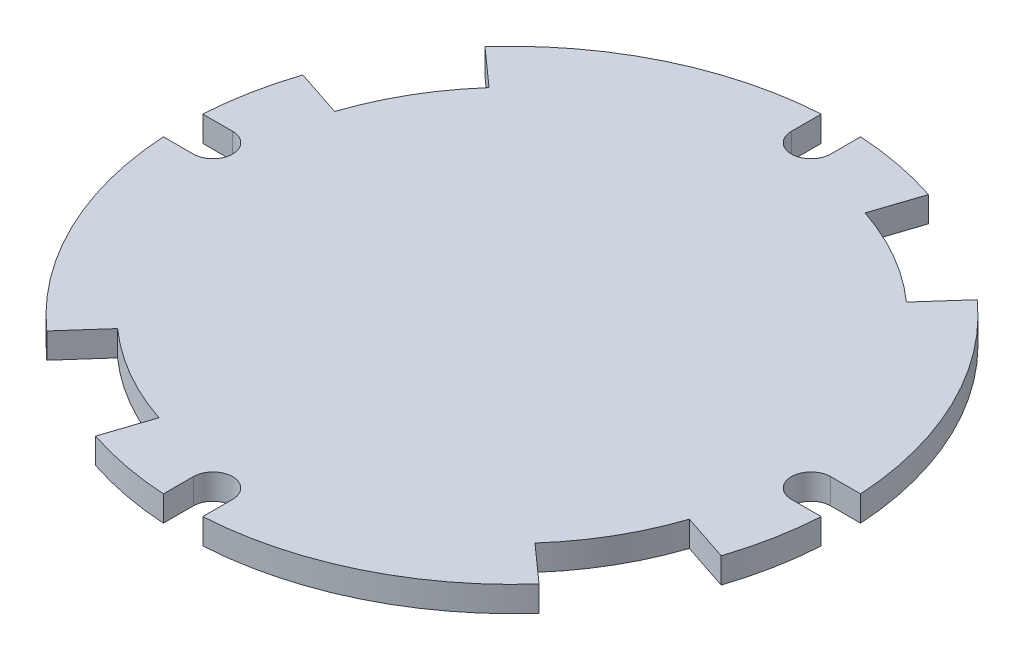
from build123d import *

# Parameters (mm, degrees)
ESQUISSE1_R                  = 25.95
BOSS_EXTRU_1_DEPTH           = 2
ENL_V_MAT_EXTRU_8_DEPTH      = 2
R_P_TITION_CIRCULAIRE1_COUNT = 4


with BuildPart() as part:
    # Esquisse1 → Boss.-Extru.1 (new body)
    with BuildSketch(Plane(origin=(0, 0, 0), x_dir=(1, 0, 0), z_dir=(0, 1, 0))):
        with Locations(Location((0, 0, 0), (0, 0, 270))):  # turned: the seam where the file's is
            Circle(ESQUISSE1_R)
    extrude(amount=BOSS_EXTRU_1_DEPTH)

    # Esquisse2 → Enlèv. mat.-Extru.8 (cut)
    with BuildSketch(Plane(origin=(0, 0, 0), x_dir=(1, 0, 0), z_dir=(0, 1, 0))):
        with BuildLine():
            Line((-1.55, 25.903667694), (-1.55, 23.55))
            ThreePointArc((-1.55, 23.55), (0, 22), (1.55, 23.55))
            Line((1.55, 23.55), (1.55, 25.903667694))
            ThreePointArc((1.55, 25.903667694), (0, 25.95), (-1.55, 25.903667694))
        make_face()
        with BuildLine():
            Line((8.160057781, 24.633634669), (6.917968061, 20.884006271))
            ThreePointArc((6.917968061, 20.884006271), (11, 19.052558883), (14.627095933, 16.433139219))
            Line((14.627095933, 16.433139219), (17.253324521, 19.383634669))
            ThreePointArc((17.253324521, 19.383634669), (12.975, 22.473359228), (8.160057781, 24.633634669))
        make_face()
    enl_v_mat_extru_8 = extrude(amount=ENL_V_MAT_EXTRU_8_DEPTH, mode=Mode.SUBTRACT)

    # Répétition circulaire1: Enlèv. mat.-Extru.8 ×4 about axis
    r_p_tition_circulaire1_axis = Axis((0, 0, 0), (0, 1, 0))
    for i in range(1, R_P_TITION_CIRCULAIRE1_COUNT):
        add(enl_v_mat_extru_8.rotate(r_p_tition_circulaire1_axis, i * 360 / R_P_TITION_CIRCULAIRE1_COUNT), mode=Mode.SUBTRACT)


solid = part.part
